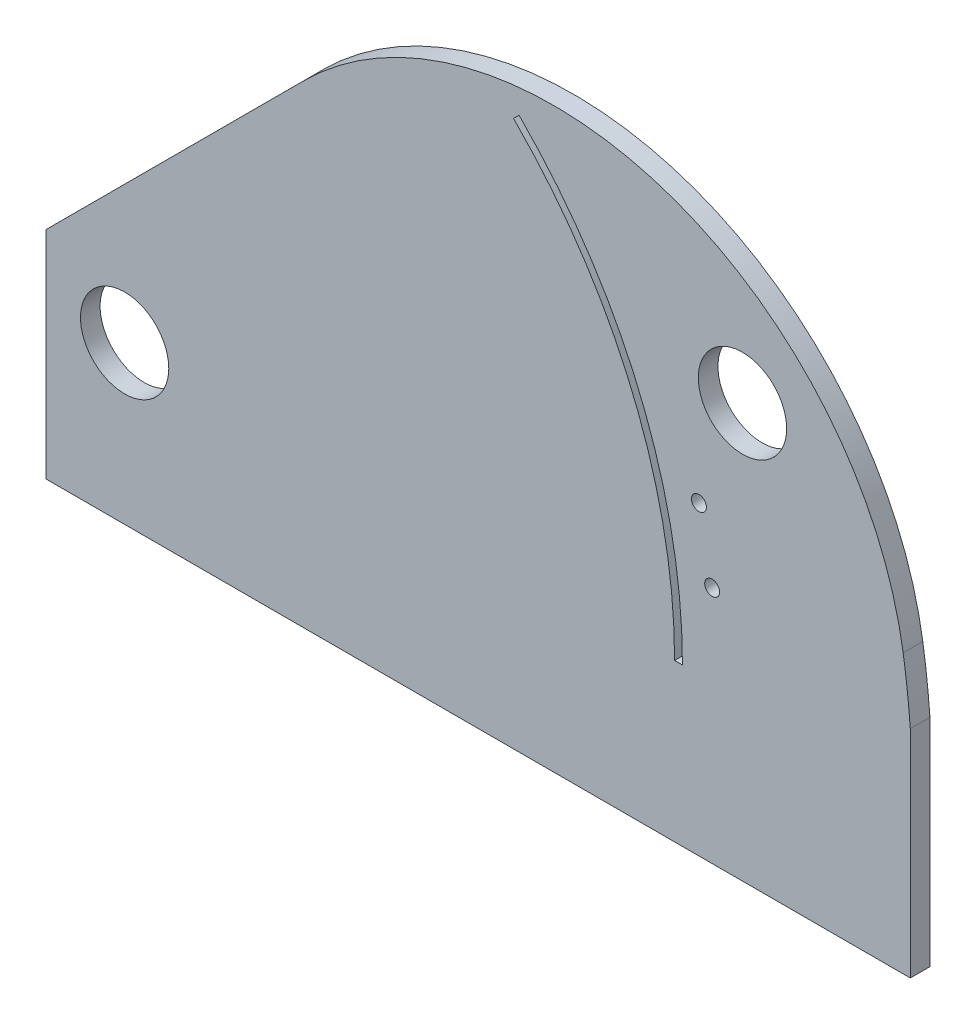
from build123d import *

# Parameters (mm, degrees)
SKETCH1_R               = 14.2748
BOSS_EXTRUDE1_DEPTH     = 6.35
CUT_EXTRUDE1_DEPTH      = 324.94514583
SKETCH3_R               = 14.2748
CUT_EXTRUDE2_DEPTH      = 324.94514583
CUT_EXTRUDE3_DEPTH      = 324.94514583
CUT_EXTRUDE3_DEPTH_BACK = 324.94514583
SKETCH5_R               = 2.413
FILLET1_R               = 114.3


with BuildPart() as part:
    # Sketch1 → Boss-Extrude1 (new body)
    with BuildSketch(Plane.XY):
        with BuildLine():
            Line((-25.4, -50.8), (254, -50.8))
            Line((254, -50.8), (254, 19.05))
            ThreePointArc((254, 19.05), (224.503557522, 120.320634806), (156.508042902, 200.958042902))
            Line((156.508042902, 200.958042902), (-25.4, 19.05))
            Line((-25.4, 19.05), (-25.4, -50.8))
        make_face()
        Circle(SKETCH1_R, mode=Mode.SUBTRACT)
    extrude(amount=BOSS_EXTRUDE1_DEPTH)

    # Sketch2 → Cut-Extrude1 (cut, through all)
    with BuildSketch(Plane.XY.offset(6.35)):
        with BuildLine():
            ThreePointArc((180.34, 0), (166.612434893, 69.013130193), (127.519636919, 127.519636919))
            Line((127.519636919, 127.519636919), (125.723585695, 125.723585695))
            ThreePointArc((125.723585695, 125.723585695), (164.265780881, 68.041114275), (177.8, 0))
            Line((177.8, 0), (180.34, 0))
        make_face()
    extrude(amount=-CUT_EXTRUDE1_DEPTH, mode=Mode.SUBTRACT)

    # Sketch3 → Cut-Extrude2 (cut, through all)
    with BuildSketch(Plane.XY.offset(6.35)):
        with Locations((199.741193703, 83.004946712)):
            Circle(SKETCH3_R)
    extrude(amount=-CUT_EXTRUDE2_DEPTH, mode=Mode.SUBTRACT)

    # Sketch5 → Cut-Extrude3 (cut, two sides: drawn at the far end of the back side and taken through both)
    with BuildSketch(Plane.XY.offset(6.35).offset(-CUT_EXTRUDE3_DEPTH_BACK)):
        with Locations((185.661672995, 48.015373378)):
            Circle(SKETCH5_R)
        with Locations((189.940787606, 26.424044045)):
            Circle(SKETCH5_R)
    extrude(amount=CUT_EXTRUDE3_DEPTH + CUT_EXTRUDE3_DEPTH_BACK, mode=Mode.SUBTRACT)

    # Fillet1
    fillet1_edges = [part.edges().sort_by_distance(p)[0] for p in [
        (156.508042902, 200.958042902, 3.175),
    ]]
    fillet(fillet1_edges, radius=FILLET1_R)


solid = part.part
